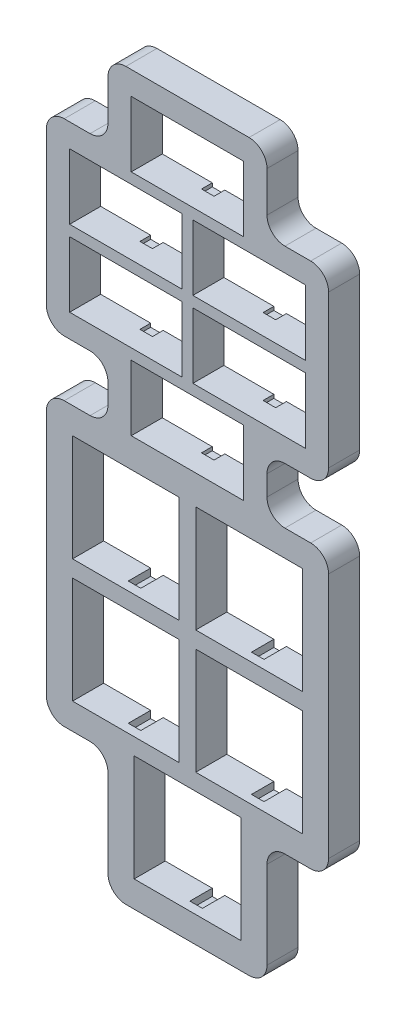
from build123d import *

# Parameters (mm, degrees)
SKETCH1_W           = 15.113
SKETCH1_H           = 15.113
SKETCH1_W_2         = 15.9385
SKETCH1_H_2         = 9.271
BOSS_EXTRUDE1_DEPTH = 4.4025
EXTRUDE_THIN1_DEPTH = 4.4025
FILLET1_R           = 2.54
SKETCH5_W           = 1.778
SKETCH5_H           = 0.761037683
CUT_EXTRUDE1_DEPTH  = 1.524
SKETCH6_W           = 1.778
SKETCH6_H           = 1.27
CUT_EXTRUDE2_DEPTH  = 3.175


with BuildPart() as part:
    # Sketch1 → Boss-Extrude1 (new body)
    with BuildSketch(Plane.XY):
        Polygon((30.95625, -37.7825), (39.6875, -37.7825), (39.6875, -16.1925), (30.95625, -16.1925), (30.95625, -5.3975), (13.49375, -5.3975), (13.49375, -16.1925), (4.7625, -16.1925), (4.7625, -37.7825), (13.49375, -37.7825), (13.49375, -48.5775), (13.49375, -50.8), (4.7625, -50.8), (4.7625, -85.725), (13.49375, -85.725), (13.49375, -103.1875), (30.95625, -103.1875), (30.95625, -85.725), (39.6875, -85.725), (39.6875, -50.8), (30.95625, -50.8), (30.95625, -48.5775), align=None)
        with Locations((22.225, -94.45625)):
            Rectangle(SKETCH1_W, SKETCH1_H, mode=Mode.SUBTRACT)
        with Locations((13.49375, -76.99375)):
            Rectangle(SKETCH1_W, SKETCH1_H, mode=Mode.SUBTRACT)
        with Locations((30.95625, -76.99375)):
            Rectangle(SKETCH1_W, SKETCH1_H, mode=Mode.SUBTRACT)
        with Locations((30.95625, -59.53125)):
            Rectangle(SKETCH1_W, SKETCH1_H, mode=Mode.SUBTRACT)
        with Locations((13.49375, -59.53125)):
            Rectangle(SKETCH1_W, SKETCH1_H, mode=Mode.SUBTRACT)
        with Locations((22.225, -43.18)):
            Rectangle(SKETCH1_W_2, SKETCH1_H_2, mode=Mode.SUBTRACT)
        with Locations((13.49375, -32.385)):
            Rectangle(SKETCH1_W_2, SKETCH1_H_2, mode=Mode.SUBTRACT)
        with Locations((13.49375, -21.59)):
            Rectangle(SKETCH1_W_2, SKETCH1_H_2, mode=Mode.SUBTRACT)
        with Locations((22.225, -10.795)):
            Rectangle(SKETCH1_W_2, SKETCH1_H_2, mode=Mode.SUBTRACT)
        with Locations((30.95625, -21.59)):
            Rectangle(SKETCH1_W_2, SKETCH1_H_2, mode=Mode.SUBTRACT)
        with Locations((30.95625, -32.385)):
            Rectangle(SKETCH1_W_2, SKETCH1_H_2, mode=Mode.SUBTRACT)
    extrude(amount=-BOSS_EXTRUDE1_DEPTH)

    # Sketch4 → Extrude-Thin1 (add, through all)
    with BuildSketch(Plane(origin=(0, 0, -4.4025), x_dir=(-1, 0, 0), z_dir=(0, 0, -1))):
        Polygon((-33.49625, -40.3225), (-33.49625, -48.26), (-42.2275, -48.26), (-42.2275, -88.265), (-33.49625, -88.265), (-33.49625, -105.7275), (-10.95375, -105.7275), (-10.95375, -88.265), (-2.2225, -88.265), (-2.2225, -48.26), (-10.95375, -48.26), (-10.95375, -40.3225), (-2.2225, -40.3225), (-2.2225, -13.6525), (-10.95375, -13.6525), (-10.95375, -2.8575), (-33.49625, -2.8575), (-33.49625, -13.6525), (-42.2275, -13.6525), (-42.2275, -40.3225), align=None)
        Polygon((-30.95625, -37.7825), (-30.95625, -50.8), (-39.6875, -50.8), (-39.6875, -85.725), (-30.95625, -85.725), (-30.95625, -103.1875), (-13.49375, -103.1875), (-13.49375, -85.725), (-4.7625, -85.725), (-4.7625, -50.8), (-13.49375, -50.8), (-13.49375, -37.7825), (-4.7625, -37.7825), (-4.7625, -16.1925), (-13.49375, -16.1925), (-13.49375, -5.3975), (-30.95625, -5.3975), (-30.95625, -16.1925), (-39.6875, -16.1925), (-39.6875, -37.7825), align=None, mode=Mode.SUBTRACT)
    extrude(amount=-EXTRUDE_THIN1_DEPTH)

    # Fillet1
    fillet1_edges = [part.edges().sort_by_distance(p)[0] for p in [
        (33.49625, -40.3225, -2.20125),
        (42.2275, -40.3225, -2.20125),
        (42.2275, -13.6525, -2.20125),
        (33.49625, -13.6525, -2.20125),
        (33.49625, -2.8575, -2.20125),
        (10.95375, -2.8575, -2.20125),
        (10.95375, -13.6525, -2.20125),
        (2.2225, -13.6525, -2.20125),
        (2.2225, -40.3225, -2.20125),
        (10.95375, -40.3225, -2.20125),
        (10.95375, -48.26, -2.20125),
        (2.2225, -48.26, -2.20125),
        (2.2225, -88.265, -2.20125),
        (10.95375, -88.265, -2.20125),
        (10.95375, -105.7275, -2.20125),
        (33.49625, -105.7275, -2.20125),
        (33.49625, -88.265, -2.20125),
        (42.2275, -88.265, -2.20125),
        (42.2275, -48.26, -2.20125),
        (33.49625, -48.26, -2.20125),
    ]]
    fillet(fillet1_edges, radius=FILLET1_R)

    # Sketch5 → Cut-Extrude1 (cut)
    with BuildSketch(Plane(origin=(0, 0, -4.4025), x_dir=(-1, 0, 0), z_dir=(0, 0, -1))):
        with Locations((-25.955625, -6.032981159)):
            Rectangle(SKETCH5_W, SKETCH5_H)
        with Locations((-18.494375, -6.032981159)):
            Rectangle(SKETCH5_W, SKETCH5_H)
        with Locations((-22.225, -15.557018841)):
            Rectangle(SKETCH5_W, SKETCH5_H)
        with Locations((-34.686875, -16.827981159)):
            Rectangle(SKETCH5_W, SKETCH5_H)
        with Locations((-27.225625, -16.827981159)):
            Rectangle(SKETCH5_W, SKETCH5_H)
        with Locations((-30.95625, -26.352018842)):
            Rectangle(SKETCH5_W, SKETCH5_H)
        with Locations((-13.49375, -26.352018842)):
            Rectangle(SKETCH5_W, SKETCH5_H)
        with Locations((-17.224375, -16.827981159)):
            Rectangle(SKETCH5_W, SKETCH5_H)
        with Locations((-9.763125, -16.827981159)):
            Rectangle(SKETCH5_W, SKETCH5_H)
        with Locations((-30.95625, -37.147018841)):
            Rectangle(SKETCH5_W, SKETCH5_H)
        with Locations((-27.225625, -27.622981159)):
            Rectangle(SKETCH5_W, SKETCH5_H)
        with Locations((-9.763125, -27.622981159)):
            Rectangle(SKETCH5_W, SKETCH5_H)
        with Locations((-17.224375, -27.622981159)):
            Rectangle(SKETCH5_W, SKETCH5_H)
        with Locations((-13.49375, -37.147018841)):
            Rectangle(SKETCH5_W, SKETCH5_H)
        with Locations((-34.686875, -27.622981159)):
            Rectangle(SKETCH5_W, SKETCH5_H)
        with Locations((-22.225, -47.942018842)):
            Rectangle(SKETCH5_W, SKETCH5_H)
        with Locations((-25.955625, -38.417981158)):
            Rectangle(SKETCH5_W, SKETCH5_H)
        with Locations((-18.494375, -38.417981158)):
            Rectangle(SKETCH5_W, SKETCH5_H)
    extrude(amount=-CUT_EXTRUDE1_DEPTH, mode=Mode.SUBTRACT)

    # Sketch6 → Cut-Extrude2 (cut)
    with BuildSketch(Plane(origin=(0, 0, -4.4025), x_dir=(-1, 0, 0), z_dir=(0, 0, -1))):
        with Locations((-34.4805, -51.59375)):
            Rectangle(SKETCH6_W, SKETCH6_H)
        with Locations((-27.432, -51.59375)):
            Rectangle(SKETCH6_W, SKETCH6_H)
        with Locations((-30.95625, -67.46875)):
            Rectangle(SKETCH6_W, SKETCH6_H)
        with Locations((-9.9695, -51.59375)):
            Rectangle(SKETCH6_W, SKETCH6_H)
        with Locations((-13.49375, -67.46875)):
            Rectangle(SKETCH6_W, SKETCH6_H)
        with Locations((-17.018, -51.59375)):
            Rectangle(SKETCH6_W, SKETCH6_H)
        with Locations((-30.95625, -84.93125)):
            Rectangle(SKETCH6_W, SKETCH6_H)
        with Locations((-13.49375, -84.93125)):
            Rectangle(SKETCH6_W, SKETCH6_H)
        with Locations((-34.4805, -69.05625)):
            Rectangle(SKETCH6_W, SKETCH6_H)
        with Locations((-9.9695, -69.05625)):
            Rectangle(SKETCH6_W, SKETCH6_H)
        with Locations((-17.018, -69.05625)):
            Rectangle(SKETCH6_W, SKETCH6_H)
        with Locations((-27.432, -69.05625)):
            Rectangle(SKETCH6_W, SKETCH6_H)
        with Locations((-25.74925, -86.51875)):
            Rectangle(SKETCH6_W, SKETCH6_H)
        with Locations((-22.225, -102.39375)):
            Rectangle(SKETCH6_W, SKETCH6_H)
        with Locations((-18.70075, -86.51875)):
            Rectangle(SKETCH6_W, SKETCH6_H)
    extrude(amount=-CUT_EXTRUDE2_DEPTH, mode=Mode.SUBTRACT)


solid = part.part
